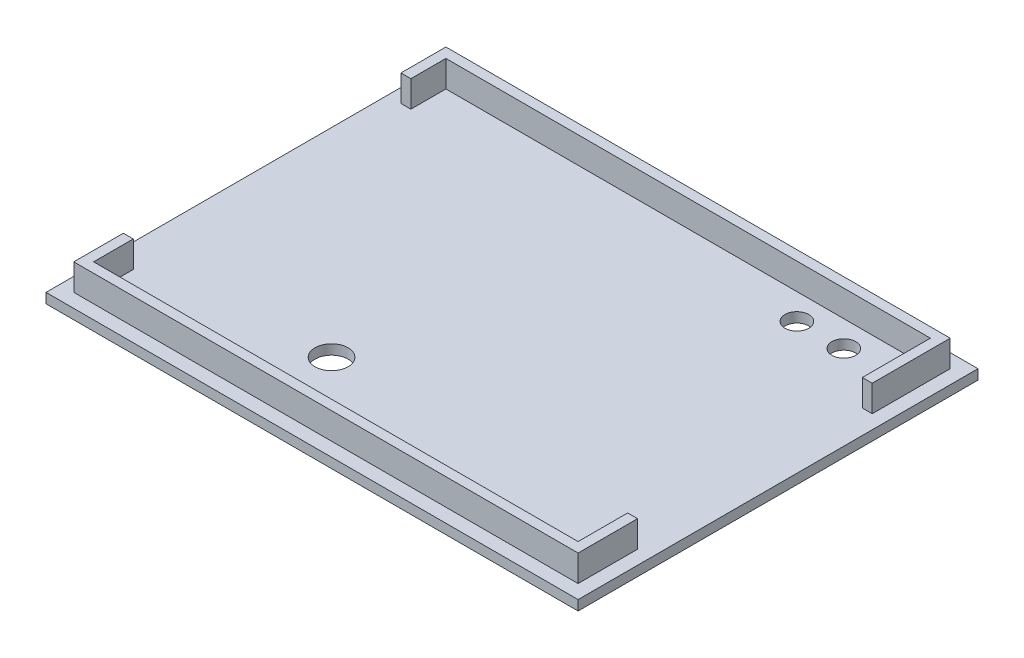
from build123d import *

# Parameters (mm, degrees)
SKETCH_1_W          = 80.5
SKETCH_1_H          = 60.5
EXTRUDE_1_DEPTH     = 1.5
SKETCH_2_W          = 76.3
SKETCH_2_H          = 56.3
SKETCH_2_W_2        = 73.3
SKETCH_2_H_2        = 53.3
EXTRUDE_2_DEPTH     = 4
SKETCH_4_W          = 2
SKETCH_4_H          = 35.5
SKETCH_4_H_2        = 42
CUT_EXTRUDE_1_DEPTH = 4
SKETCH_5_R          = 1.8
SKETCH_5_R_2        = 2.5
CUT_EXTRUDE_2_DEPTH = 3


with BuildPart() as part:
    # 草图1 → 凸台-拉伸1 (new body)
    with BuildSketch(Plane(origin=(0, 0, 0), x_dir=(1, 0, 0), z_dir=(0, 1, 0))):
        Rectangle(SKETCH_1_W, SKETCH_1_H)
    extrude(amount=EXTRUDE_1_DEPTH)

    # 草图2 → 凸台-拉伸2 (add)
    with BuildSketch(Plane(origin=(0, 1.5, 0), x_dir=(1, 0, 0), z_dir=(0, 1, 0))):
        Rectangle(SKETCH_2_W, SKETCH_2_H)
        Rectangle(SKETCH_2_W_2, SKETCH_2_H_2, mode=Mode.SUBTRACT)
    extrude(amount=EXTRUDE_2_DEPTH)

    # 草图4 → 切除-拉伸1 (cut)
    with BuildSketch(Plane(origin=(0, 5.5, 0), x_dir=(1, 0, 0), z_dir=(0, 1, 0))):
        with Locations((37.4, -1.4)):
            Rectangle(SKETCH_4_W, SKETCH_4_H)
        with Locations((-37.4, 0.35)):
            Rectangle(SKETCH_4_W, SKETCH_4_H_2)
    extrude(amount=-CUT_EXTRUDE_1_DEPTH, mode=Mode.SUBTRACT)

    # 草图5 → 切除-拉伸2 (cut)
    with BuildSketch(Plane.XZ):
        with Locations((20.35, -22.75)):
            Circle(SKETCH_5_R)
        with Locations((27.45, -22.75)):
            Circle(SKETCH_5_R)
        with Locations((-10.15, 17.15)):
            Circle(SKETCH_5_R_2)
    extrude(amount=-CUT_EXTRUDE_2_DEPTH, mode=Mode.SUBTRACT)


solid = part.part
